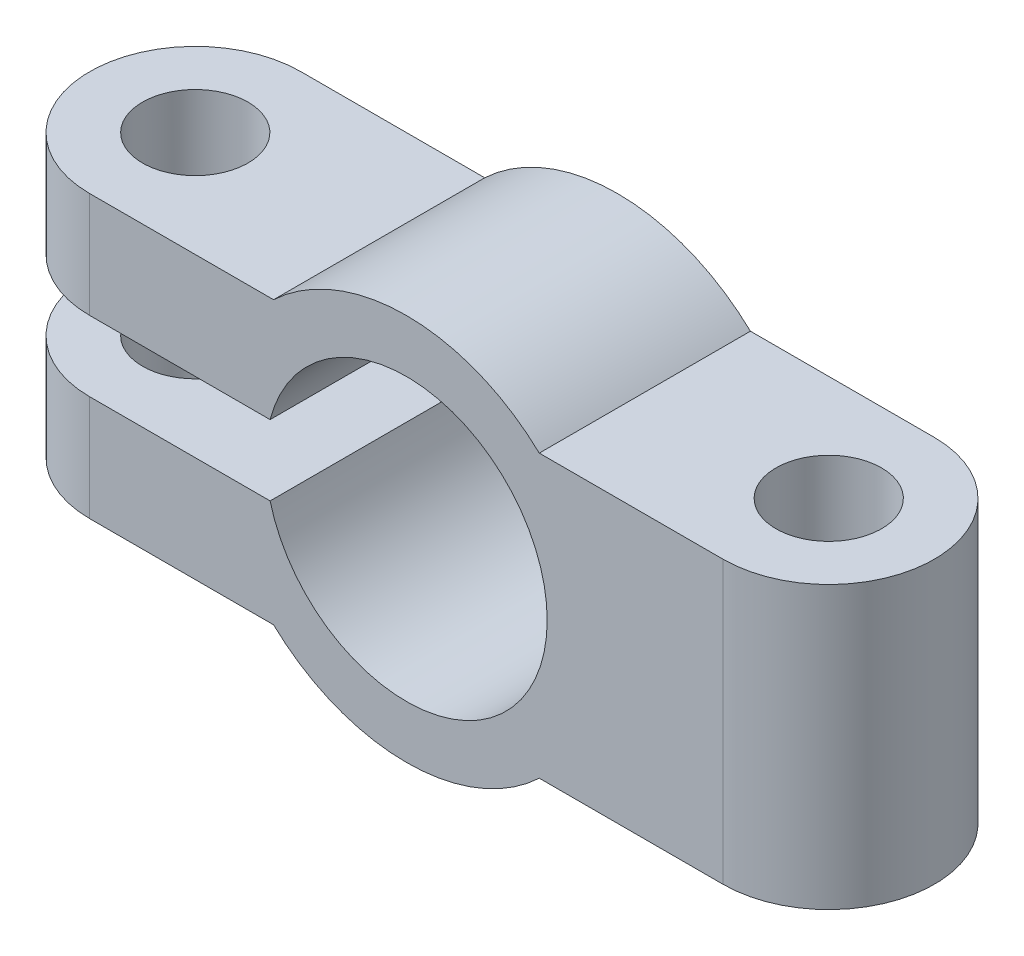
from build123d import *

# Parameters (mm, degrees)
EXTRUDE_1_DEPTH     = 6
CUT_EXTRUDE_1_DEPTH = 10.5
SKETCH_3_R          = 1.5
CUT_EXTRUDE_2_DEPTH = 10.5


with BuildPart() as part:
    # 草图1 → 凸台-拉伸1 (new body)
    with BuildSketch(Plane.XY):
        with BuildLine():
            Line((12, 4), (12, -4))
            Line((12, -4), (3.774917218, -4))
            ThreePointArc((3.774917218, -4), (0, -5.5), (-3.774917218, -4))
            Line((-3.774917218, -4), (-12, -4))
            Line((-12, -4), (-12, -1))
            Line((-12, -1), (-3.872983346, -1))
            ThreePointArc((-3.872983346, -1), (4, 0), (-3.872983346, 1))
            Line((-3.872983346, 1), (-12, 1))
            Line((-12, 1), (-12, 4))
            Line((-12, 4), (-3.774917218, 4))
            ThreePointArc((-3.774917218, 4), (0, 5.5), (3.774917218, 4))
            Line((3.774917218, 4), (12, 4))
        make_face()
    extrude(amount=EXTRUDE_1_DEPTH)

    # 草图2 → 切除-拉伸1 (cut, through all)
    with BuildSketch(Plane.XZ.offset(4)):
        with BuildLine():
            ThreePointArc((-9, 0), (-11.121320344, 0.878679656), (-12, 3))
            Line((-12, 3), (-12, 0))
            Line((-12, 0), (-9, 0))
        make_face()
        with BuildLine():
            Line((-9, 6), (-12, 6))
            Line((-12, 6), (-12, 3))
            ThreePointArc((-12, 3), (-11.121320344, 5.121320344), (-9, 6))
        make_face()
        with BuildLine():
            Line((12, 0), (12, 3))
            ThreePointArc((12, 3), (11.121320344, 0.878679656), (9, 0))
            Line((9, 0), (12, 0))
        make_face()
        with BuildLine():
            Line((12, 6), (9, 6))
            ThreePointArc((9, 6), (11.121320344, 5.121320344), (12, 3))
            Line((12, 3), (12, 6))
        make_face()
    extrude(amount=-CUT_EXTRUDE_1_DEPTH, mode=Mode.SUBTRACT)

    # 草图3 → 切除-拉伸2 (cut, through all)
    with BuildSketch(Plane.XZ.offset(4)):
        with Locations((-9, 3)):
            Circle(SKETCH_3_R)
        with Locations((9, 3)):
            Circle(SKETCH_3_R)
    extrude(amount=-CUT_EXTRUDE_2_DEPTH, mode=Mode.SUBTRACT)


solid = part.part
